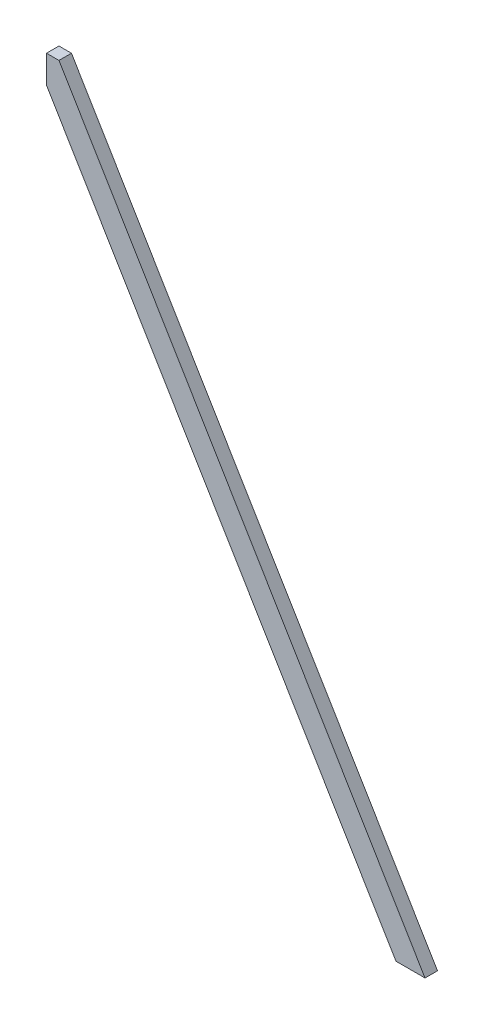
from build123d import *

# Parameters (mm, degrees)
BOSS_EXTRUDE1_DEPTH = 19.05
CUT_EXTRUDE1_DEPTH  = 20.05


with BuildPart() as part:
    # Sketch1 → Boss-Extrude1 (new body)
    with BuildSketch(Plane.XY):
        Polygon((559.054, 0), (-18.796, 965.516993591), (-18.796, 891.326264322), (514.651764521, 0), align=None)
    extrude(amount=-BOSS_EXTRUDE1_DEPTH)

    # Sketch2 → Cut-Extrude1 (cut, through all)
    with BuildSketch(Plane.XY):
        Polygon((-18.796, 965.516993591), (-18.796, 933.686763034), (0.254, 933.686763034), align=None)
    extrude(amount=-CUT_EXTRUDE1_DEPTH, mode=Mode.SUBTRACT)


solid = part.part
